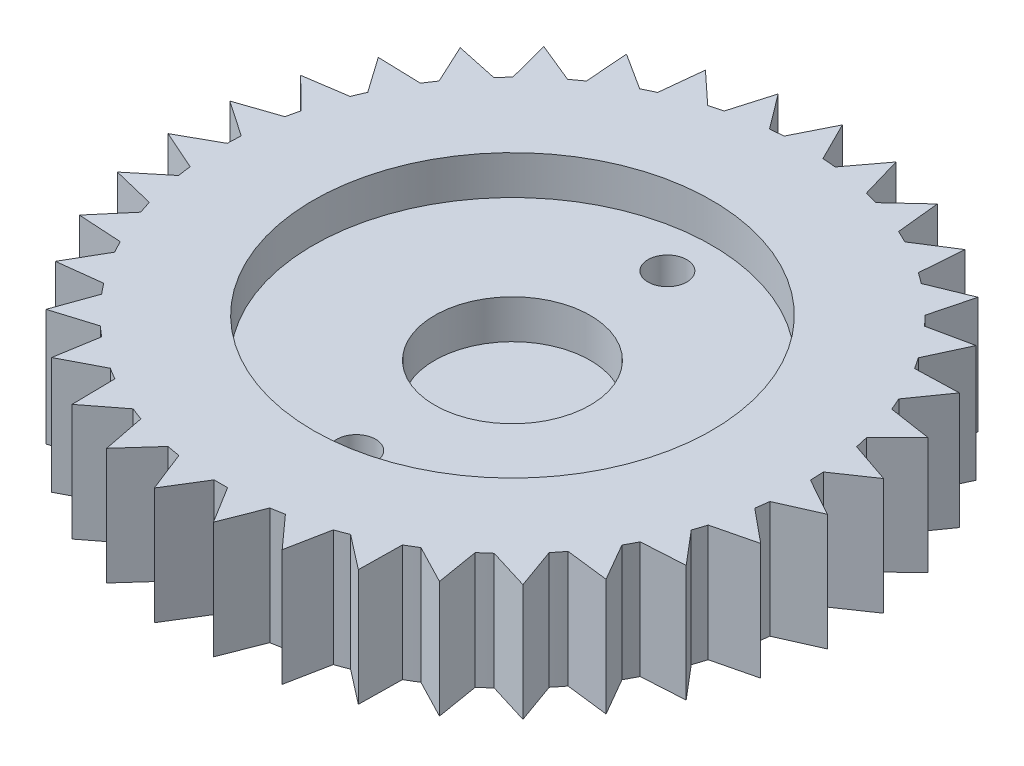
from build123d import *

# Parameters (mm, degrees)
SKETCH_1_R          = 15
EXTRUDE_1_DEPTH     = 6
EXTRUDE_2_DEPTH     = 6
SKETCH_3_R          = 1
CUT_EXTRUDE_1_DEPTH = 6
SKETCH_4_R          = 10.25
CUT_EXTRUDE_2_DEPTH = 2
SKETCH_5_R          = 4
CUT_EXTRUDE_3_DEPTH = 2


with BuildPart() as part:
    # 草图1 → 凸台-拉伸1 (new body)
    with BuildSketch(Plane(origin=(0, 0, 0), x_dir=(1, 0, 0), z_dir=(0, 1, 0))):
        Circle(SKETCH_1_R)
    extrude(amount=EXTRUDE_1_DEPTH)

    # 草图2 → 凸台-拉伸2 (add)
    with BuildSketch(Plane(origin=(0, 6, 0), x_dir=(1, 0, 0), z_dir=(0, 1, 0))):
        Polygon((0, 16.966629547), (-1, 14.966629547), (-1, 14.940773363), (1, 14.940773363), (1, 14.966629547), align=None)
        Polygon((3.656324486, 14.547552758), (3.029508687, 16.69396883), (1.688465309, 14.904666548), (1.683848509, 14.879225883), (3.651707686, 14.522112094), align=None)
        Polygon((6.195131695, 13.660905654), (5.961646472, 15.884750219), (4.322661954, 14.363655302), (4.313576741, 14.339447841), (6.186046483, 13.636698193), align=None)
        Polygon((8.534822274, 12.335185802), (8.702172035, 14.564982666), (6.817924686, 13.360984356), (6.804663068, 13.338788146), (8.521560655, 12.312989592), align=None)
        Polygon((10.600196642, 10.613002928), (11.163002628, 12.777084586), (9.09405371, 11.92888038), (9.077041925, 11.909408826), (10.583184857, 10.593531374), align=None)
        Polygon((12.324871968, 8.549709408), (13.265045131, 10.578520495), (11.077892365, 10.113372373), (11.057677186, 10.097251306), (12.30465679, 8.533588341), align=None)
        Polygon((13.653415769, 6.211621193), (14.94073817, 8.03995405), (12.705678444, 7.972812257), (12.682909604, 7.960559822), (13.630646929, 6.199368758), align=None)
        Polygon((14.543127552, 3.673886362), (16.13622359, 5.242976867), (13.925093563, 5.575999395), (13.900502871, 5.568009395), (14.51853686, 3.665896362), align=None)
        Polygon((14.96541125, 1.018069801), (16.813077508, 2.277486094), (14.696944718, 2.999969324), (14.671322539, 2.996498564), (14.939789071, 1.014599041), align=None)
        Polygon((14.906694317, -1.670468362), (16.94954528, -0.761204956), (14.996423977, 0.327517771), (14.970593829, 0.328677804), (14.880864168, -1.669308329), align=None)
        Polygon((14.368863963, -4.305316297), (16.541240721, -3.775430253), (14.813905831, -2.355460473), (14.788697915, -2.349706931), (14.343656047, -4.299562755), align=None)
        Polygon((13.369206498, -6.801787824), (15.601287075, -6.668310115), (14.155256562, -4.962732279), (14.131481082, -4.952570151), (13.345431019, -6.791625697), align=None)
        Polygon((11.939851737, -9.079644294), (14.159895226, -9.346865003), (13.0416457, -7.410497786), (13.02006682, -7.396253693), (11.918272857, -9.0654002), align=None)
        Polygon((10.126740316, -11.065673525), (12.263392693, -11.725003959), (11.508865614, -9.620083797), (11.490176897, -9.602215554), (10.1080516, -11.047805282), align=None)
        Polygon((7.98814713, -12.696042904), (9.972734629, -13.726291641), (9.606181119, -11.5204724), (9.590983235, -11.499554308), (7.972949246, -12.675124812), align=None)
        Polygon((5.592808322, -13.918351018), (7.361544668, -15.286405015), (7.394746058, -13.05058354), (7.38352748, -13.027287923), (5.581589744, -13.895055402), align=None)
        Polygon((3.017712053, -14.693311879), (4.513748605, -16.355200755), (4.945637774, -14.161238188), (4.938759077, -14.136313787), (3.010833355, -14.668387478), align=None)
        Polygon((0.345624035, -14.996017606), (1.520876947, -16.898326885), (2.337572623, -14.816738988), (2.335254893, -14.790986893), (0.343306305, -14.970265511), align=None)
        Polygon((-2.337572623, -14.816738988), (-1.520876947, -16.898326885), (-0.345624035, -14.996017606), (-0.343306305, -14.970265511), (-2.335254893, -14.790986893), align=None)
        Polygon((-4.945637774, -14.161238188), (-4.513748605, -16.355200755), (-3.017712053, -14.693311879), (-3.010833355, -14.668387478), (-4.938759077, -14.136313787), align=None)
        Polygon((-7.394746058, -13.05058354), (-7.361544668, -15.286405015), (-5.592808322, -13.918351018), (-5.581589744, -13.895055402), (-7.38352748, -13.027287923), align=None)
        Polygon((-9.606181119, -11.5204724), (-9.972734629, -13.726291641), (-7.98814713, -12.696042904), (-7.972949246, -12.675124812), (-9.590983235, -11.499554308), align=None)
        Polygon((-11.508865614, -9.620083797), (-12.263392693, -11.725003959), (-10.126740316, -11.065673525), (-10.108051599, -11.047805282), (-11.490176897, -9.602215554), align=None)
        Polygon((-13.0416457, -7.410497786), (-14.159895226, -9.346865003), (-11.939851737, -9.079644294), (-11.918272857, -9.0654002), (-13.02006682, -7.396253693), align=None)
        Polygon((-14.155256562, -4.962732279), (-15.601287075, -6.668310115), (-13.369206498, -6.801787824), (-13.345431019, -6.791625697), (-14.131481082, -4.952570151), align=None)
        Polygon((-14.813905831, -2.355460473), (-16.541240721, -3.775430253), (-14.368863963, -4.305316297), (-14.343656047, -4.299562755), (-14.788697915, -2.349706931), align=None)
        Polygon((-14.996423977, 0.327517771), (-16.94954528, -0.761204956), (-14.906694317, -1.670468362), (-14.880864168, -1.669308329), (-14.970593829, 0.328677804), align=None)
        Polygon((-14.696944718, 2.999969324), (-16.813077508, 2.277486094), (-14.96541125, 1.018069801), (-14.939789071, 1.014599041), (-14.671322539, 2.996498564), align=None)
        Polygon((-13.925093563, 5.575999395), (-16.13622359, 5.242976867), (-14.543127552, 3.673886362), (-14.51853686, 3.665896362), (-13.900502871, 5.568009395), align=None)
        Polygon((-12.705678444, 7.972812257), (-14.94073817, 8.03995405), (-13.653415769, 6.211621193), (-13.630646929, 6.199368758), (-12.682909604, 7.960559822), align=None)
        Polygon((-11.077892364, 10.113372373), (-13.265045131, 10.578520495), (-12.324871968, 8.549709408), (-12.30465679, 8.533588341), (-11.057677186, 10.097251306), align=None)
        Polygon((-9.09405371, 11.92888038), (-11.163002628, 12.777084586), (-10.600196642, 10.613002928), (-10.583184857, 10.593531374), (-9.077041925, 11.909408826), align=None)
        Polygon((-6.817924686, 13.360984356), (-8.702172035, 14.564982666), (-8.534822274, 12.335185802), (-8.521560655, 12.312989592), (-6.804663068, 13.338788146), align=None)
        Polygon((-4.322661954, 14.363655302), (-5.961646472, 15.884750219), (-6.195131695, 13.660905654), (-6.186046483, 13.636698193), (-4.313576741, 14.339447841), align=None)
        Polygon((-1.688465309, 14.904666548), (-3.029508687, 16.69396883), (-3.656324486, 14.547552758), (-3.651707686, 14.522112094), (-1.683848509, 14.879225883), align=None)
    extrude(amount=-EXTRUDE_2_DEPTH)

    # 草图3 → 切除-拉伸1 (cut)
    with BuildSketch(Plane(origin=(0, 6, 0), x_dir=(1, 0, 0), z_dir=(0, 1, 0))):
        with Locations((0, 7.966629547)):
            Circle(SKETCH_3_R)
        with Locations((0, -8.033370453)):
            Circle(SKETCH_3_R)
    extrude(amount=-CUT_EXTRUDE_1_DEPTH, mode=Mode.SUBTRACT)

    # 草图4 → 切除-拉伸2 (cut)
    with BuildSketch(Plane(origin=(0, 6, 0), x_dir=(1, 0, 0), z_dir=(0, 1, 0))):
        Circle(SKETCH_4_R)
    extrude(amount=-CUT_EXTRUDE_2_DEPTH, mode=Mode.SUBTRACT)

    # 草图5 → 切除-拉伸3 (cut)
    with BuildSketch(Plane(origin=(0, 4, 0), x_dir=(1, 0, 0), z_dir=(0, 1, 0))):
        Circle(SKETCH_5_R)
    extrude(amount=-CUT_EXTRUDE_3_DEPTH, mode=Mode.SUBTRACT)


solid = part.part
